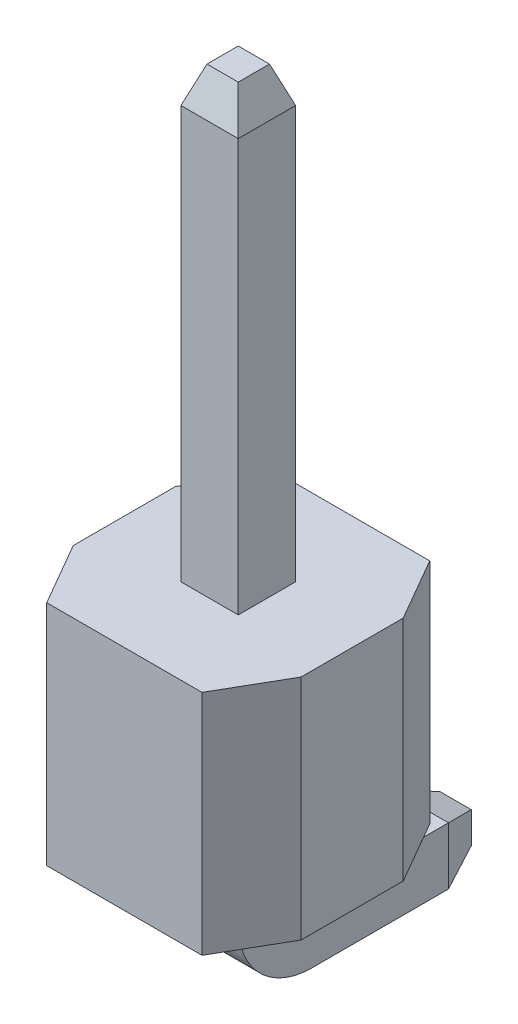
from build123d import *
from OCP.BRepFilletAPI import BRepFilletAPI_MakeChamfer

# Parameters (mm, degrees)
SKETCH2_W      = 0.64
SKETCH2_H      = 0.64
CHAMFER1_SIZE  = 0.4
CHAMFER1_SIZE2 = 0.145588094
SKETCH6_W      = 2.54
SKETCH6_H      = 2.54
EXTRUDE1_DEPTH = 2.54
CHAMFER2_SIZE  = 0.7
CHAMFER2_SIZE2 = 0.404145188


with BuildPart() as part:
    # Sweep1: sweep along a path in Sketch1
    with BuildLine(Plane(origin=(0, 0, 0), x_dir=(0, 0, -1), z_dir=(1, 0, 0))) as sweep1_path:
        Line((0, -5.359515774), (-1.924260195, -5.359515774))
        ThreePointArc((-1.924260195, -5.359515774), (-2.277813586, -5.213069164), (-2.424260195, -4.859515774))
        Line((-2.424260195, -4.859515774), (-2.424260195, 3.140484226))
    # Sketch2 → Sweep1 (sweep)
    with BuildSketch(Plane.XY):
        with Locations((0, -5.359515774)):
            Rectangle(SKETCH2_W, SKETCH2_H)
    sweep(path=sweep1_path.line)

    # Chamfer1: one chamfer whose edges measure the first distance from different faces: ONE call of the kernel's chamfer builder (chamfer() names one face for all edges)
    chamfer1_edges_1 = [part.edges().sort_by_distance(p)[0] for p in [
        (-0.32, 3.140484226, 2.424260195),
        (-0.32, -5.359515774, 0),
    ]]
    chamfer1_side_1 = [part.faces().sort_by_distance(p)[0] for p in [
        (-0.32, -1.987926827, 2.15141447),
    ]]
    chamfer1_edges_2 = [part.edges().sort_by_distance(p)[0] for p in [
        (0, 3.140484226, 2.104260195),
    ]]
    chamfer1_side_2 = [part.faces().sort_by_distance(p)[0] for p in [
        (0, -0.859515774, 2.104260195),
    ]]
    chamfer1_edges_3 = [part.edges().sort_by_distance(p)[0] for p in [
        (0.32, 3.140484226, 2.424260195),
        (0.32, -5.359515774, 0),
    ]]
    chamfer1_side_3 = [part.faces().sort_by_distance(p)[0] for p in [
        (0.32, -1.987926827, 2.15141447),
    ]]
    chamfer1_edges_4 = [part.edges().sort_by_distance(p)[0] for p in [
        (0, 3.140484226, 2.744260195),
    ]]
    chamfer1_side_4 = [part.faces().sort_by_distance(p)[0] for p in [
        (0, -0.859515774, 2.744260195),
    ]]
    chamfer1_edges_5 = [part.edges().sort_by_distance(p)[0] for p in [
        (0, -5.039515774, 0),
    ]]
    chamfer1_side_5 = [part.faces().sort_by_distance(p)[0] for p in [
        (0, -5.039515774, 0.962130097),
    ]]
    chamfer1_edges_6 = [part.edges().sort_by_distance(p)[0] for p in [
        (0, -5.679515774, 0),
    ]]
    chamfer1_side_6 = [part.faces().sort_by_distance(p)[0] for p in [
        (0, -5.679515774, 0.962130097),
    ]]
    chamfer1 = BRepFilletAPI_MakeChamfer(part.part.solid().wrapped)
    for e in chamfer1_edges_1:
        chamfer1.Add(CHAMFER1_SIZE, CHAMFER1_SIZE2, e.wrapped, chamfer1_side_1[0].wrapped)  # the first distance lies on this face
    for e in chamfer1_edges_2:
        chamfer1.Add(CHAMFER1_SIZE, CHAMFER1_SIZE2, e.wrapped, chamfer1_side_2[0].wrapped)  # the first distance lies on this face
    for e in chamfer1_edges_3:
        chamfer1.Add(CHAMFER1_SIZE, CHAMFER1_SIZE2, e.wrapped, chamfer1_side_3[0].wrapped)  # the first distance lies on this face
    for e in chamfer1_edges_4:
        chamfer1.Add(CHAMFER1_SIZE, CHAMFER1_SIZE2, e.wrapped, chamfer1_side_4[0].wrapped)  # the first distance lies on this face
    for e in chamfer1_edges_5:
        chamfer1.Add(CHAMFER1_SIZE, CHAMFER1_SIZE2, e.wrapped, chamfer1_side_5[0].wrapped)  # the first distance lies on this face
    for e in chamfer1_edges_6:
        chamfer1.Add(CHAMFER1_SIZE, CHAMFER1_SIZE2, e.wrapped, chamfer1_side_6[0].wrapped)  # the first distance lies on this face
    add(Compound.cast(chamfer1.Shape()), mode=Mode.REPLACE)


with BuildPart() as body_2:
    # Sketch6 → Extrude1 (new body)
    with BuildSketch(Plane(origin=(0, -4.399515774, 0), x_dir=(-1, 0, 0), z_dir=(0, 1, 0))):
        with Locations((0, 2.424260195)):
            Rectangle(SKETCH6_W, SKETCH6_H)
    extrude(amount=EXTRUDE1_DEPTH)

    # Chamfer2: one chamfer whose edges measure the first distance from different faces: ONE call of the kernel's chamfer builder (chamfer() names one face for all edges)
    chamfer2_edges_1 = [body_2.edges().sort_by_distance(p)[0] for p in [
        (-1.27, -3.129515774, 1.154260195),
        (-1.27, -3.129515774, 3.694260195),
    ]]
    chamfer2_side_1 = [body_2.faces().sort_by_distance(p)[0] for p in [
        (-1.27, -3.129515774, 2.424260195),
    ]]
    chamfer2_edges_2 = [body_2.edges().sort_by_distance(p)[0] for p in [
        (1.27, -3.129515774, 1.154260195),
        (1.27, -3.129515774, 3.694260195),
    ]]
    chamfer2_side_2 = [body_2.faces().sort_by_distance(p)[0] for p in [
        (1.27, -3.129515774, 2.424260195),
    ]]
    chamfer2 = BRepFilletAPI_MakeChamfer(body_2.part.solid().wrapped)
    for e in chamfer2_edges_1:
        chamfer2.Add(CHAMFER2_SIZE, CHAMFER2_SIZE2, e.wrapped, chamfer2_side_1[0].wrapped)  # the first distance lies on this face
    for e in chamfer2_edges_2:
        chamfer2.Add(CHAMFER2_SIZE, CHAMFER2_SIZE2, e.wrapped, chamfer2_side_2[0].wrapped)  # the first distance lies on this face
    add(Compound.cast(chamfer2.Shape()), mode=Mode.REPLACE)


solid = Compound([part.part, body_2.part])
